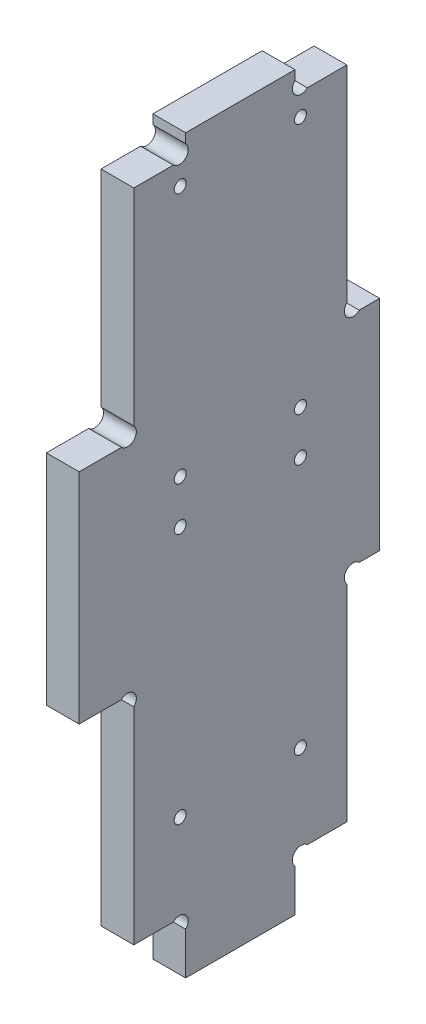
from build123d import *

# Parameters (mm, degrees)
ESQUISSE1_R      = 1.1
EXTRUSION1_DEPTH = 6


with BuildPart() as part:
    # Esquisse1 → Extrusion1 (new body)
    with BuildSketch(Plane(origin=(0, 0, 0), x_dir=(0, 0, -1), z_dir=(1, 0, 0))):
        with BuildLine():
            Line((19.5, 7.7372583), (19.5, 0))
            Line((19.5, 0), (39.5, 0))
            Line((39.5, 0), (39.5, 7.7372583))
            ThreePointArc((39.5, 7.7372583), (39.5, 10), (41.7627417, 10))
            Line((41.7627417, 10), (49, 10))
            Line((49, 10), (49, 47.7372583))
            ThreePointArc((49, 47.7372583), (49, 50), (51.2627417, 50))
            Line((51.2627417, 50), (55, 50))
            Line((55, 50), (55, 90))
            Line((55, 90), (51.2627417, 90))
            ThreePointArc((51.2627417, 90), (49, 90), (49, 92.2627417))
            Line((49, 92.2627417), (49, 130))
            Line((49, 130), (41.7627417, 130))
            ThreePointArc((41.7627417, 130), (39.5, 130), (39.5, 132.2627417))
            Line((39.5, 132.2627417), (39.5, 134))
            Line((39.5, 134), (19.5, 134))
            Line((19.5, 134), (19.5, 132.2627417))
            ThreePointArc((19.5, 132.2627417), (19.5, 130), (17.2372583, 130))
            Line((17.2372583, 130), (10, 130))
            Line((10, 130), (10, 92.2627417))
            ThreePointArc((10, 92.2627417), (10, 90), (7.7372583, 90))
            Line((7.7372583, 90), (0, 90))
            Line((0, 90), (0, 50))
            Line((0, 50), (7.7372583, 50))
            ThreePointArc((7.7372583, 50), (10, 50), (10, 47.7372583))
            Line((10, 47.7372583), (10, 10))
            Line((10, 10), (17.2372583, 10))
            ThreePointArc((17.2372583, 10), (19.5, 10), (19.5, 7.7372583))
        make_face()
        with Locations((18.5, 126)):
            Circle(ESQUISSE1_R, mode=Mode.SUBTRACT)
        with Locations((18.5, 80)):
            Circle(ESQUISSE1_R, mode=Mode.SUBTRACT)
        with Locations(Location((40.5, 126, 0), (0, 0, 180))):  # turned: the seam where the file's is
            Circle(ESQUISSE1_R, mode=Mode.SUBTRACT)
        with Locations(Location((40.5, 80, 0), (0, 0, 180))):  # turned: the seam where the file's is
            Circle(ESQUISSE1_R, mode=Mode.SUBTRACT)
        with Locations(Location((18.5, 72, 0), (0, 0, 180))):  # turned: the seam where the file's is
            Circle(ESQUISSE1_R, mode=Mode.SUBTRACT)
        with Locations((40.5, 72)):
            Circle(ESQUISSE1_R, mode=Mode.SUBTRACT)
        with Locations((40.5, 26)):
            Circle(ESQUISSE1_R, mode=Mode.SUBTRACT)
        with Locations(Location((18.5, 26, 0), (0, 0, 180))):  # turned: the seam where the file's is
            Circle(ESQUISSE1_R, mode=Mode.SUBTRACT)
    extrude(amount=EXTRUSION1_DEPTH)


solid = part.part
